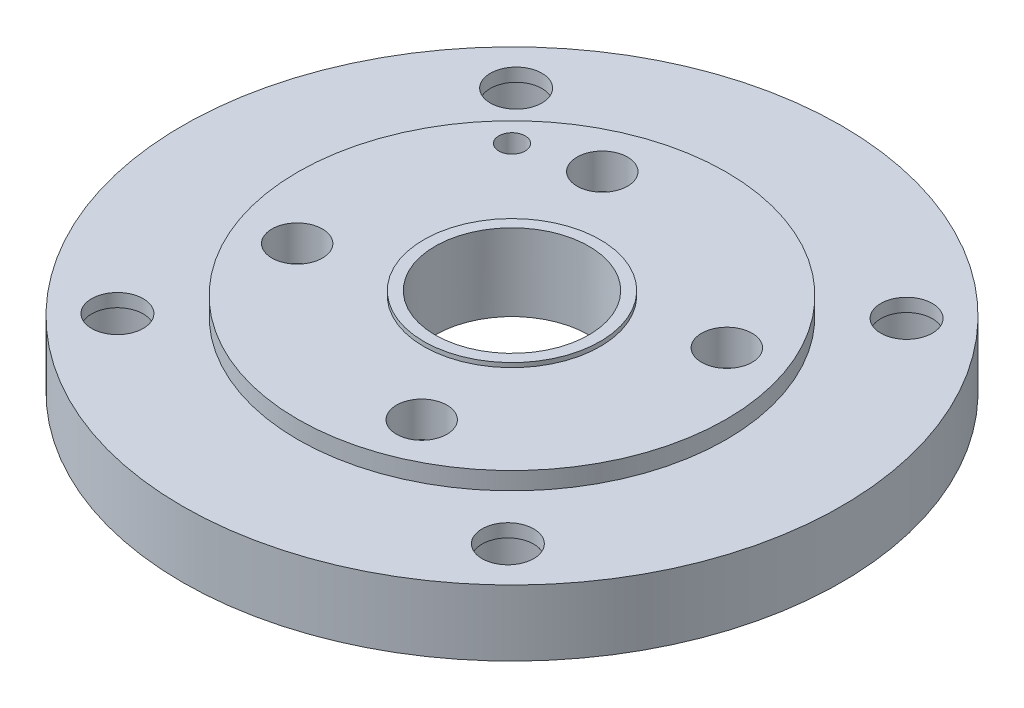
from build123d import *

# Parameters (mm, degrees)
IZIM1_R                     = 150
Y_KSEKLIK_EKSTR_ZYON1_DEPTH = 30
IZIM2_R                     = 97.5
Y_KSEKLIK_EKSTR_ZYON2_DEPTH = 8
IZIM3_R                     = 40.15
Y_KSEKLIK_EKSTR_ZYON3_DEPTH = 2
IZIM4_R                     = 35
KES_EKSTR_ZYON1_DEPTH       = 41
IZIM5_R                     = 43.5
KES_EKSTR_ZYON2_DEPTH       = 5
IZIM6_R                     = 11.5
IZIM6_R_2                   = 6
KES_EKSTR_ZYON4_DEPTH       = 16
IZIM7_R                     = 11.75
KES_EKSTR_ZYON5_DEPTH       = 31
IZIM8_R                     = 6
KES_EKSTR_ZYON6_DEPTH       = 23
IZIM9_R                     = 17.5
KES_EKSTR_ZYON7_DEPTH       = 24


with BuildPart() as part:
    # Çizim1 → Yükseklik-Ekstrüzyon1 (new body)
    with BuildSketch(Plane(origin=(0, 0, 0), x_dir=(1, 0, 0), z_dir=(0, 1, 0))):
        Circle(IZIM1_R)
    extrude(amount=Y_KSEKLIK_EKSTR_ZYON1_DEPTH)

    # Çizim2 → Yükseklik-Ekstrüzyon2 (add)
    with BuildSketch(Plane(origin=(0, 30, 0), x_dir=(1, 0, 0), z_dir=(0, 1, 0))):
        Circle(IZIM2_R)
    extrude(amount=Y_KSEKLIK_EKSTR_ZYON2_DEPTH)

    # Çizim3 → Yükseklik-Ekstrüzyon3 (add)
    with BuildSketch(Plane(origin=(0, 38, 0), x_dir=(1, 0, 0), z_dir=(0, 1, 0))):
        Circle(IZIM3_R)
    extrude(amount=Y_KSEKLIK_EKSTR_ZYON3_DEPTH)

    # Çizim4 → Kes-Ekstrüzyon1 (cut, through all)
    with BuildSketch(Plane(origin=(0, 40, 0), x_dir=(1, 0, 0), z_dir=(0, 1, 0))):
        Circle(IZIM4_R)
    extrude(amount=-KES_EKSTR_ZYON1_DEPTH, mode=Mode.SUBTRACT)

    # Çizim5 → Kes-Ekstrüzyon2 (cut)
    with BuildSketch(Plane.XZ):
        Circle(IZIM5_R)
    extrude(amount=-KES_EKSTR_ZYON2_DEPTH, mode=Mode.SUBTRACT)

    # Çizim6 → Kes-Ekstrüzyon4 (cut)
    with BuildSketch(Plane(origin=(0, 38, 0), x_dir=(1, 0, 0), z_dir=(0, 1, 0))):
        with Locations((-28.338059011, 69.440293861)):
            Circle(IZIM6_R)
        with Locations((69.440293861, 28.338059011)):
            Circle(IZIM6_R)
        with Locations((28.338059011, -69.440293861)):
            Circle(IZIM6_R)
        with Locations((-69.440293861, -28.338059011)):
            Circle(IZIM6_R)
        with Locations((-60, 60)):
            Circle(IZIM6_R_2)
    extrude(amount=-KES_EKSTR_ZYON4_DEPTH, mode=Mode.SUBTRACT)

    # Çizim7 → Kes-Ekstrüzyon5 (cut, through all)
    with BuildSketch(Plane(origin=(0, 30, 0), x_dir=(1, 0, 0), z_dir=(0, 1, 0))):
        with Locations((-88.857244245, 90.738030313)):
            Circle(IZIM7_R)
        with Locations((90.738030313, 88.857244245)):
            Circle(IZIM7_R)
        with Locations((88.857244245, -90.738030313)):
            Circle(IZIM7_R)
        with Locations((-90.738030313, -88.857244245)):
            Circle(IZIM7_R)
    extrude(amount=-KES_EKSTR_ZYON5_DEPTH, mode=Mode.SUBTRACT)

    # Çizim8 → Kes-Ekstrüzyon6 (cut, through all)
    with BuildSketch(Plane(origin=(0, 22, 0), x_dir=(1, 0, 0), z_dir=(0, 1, 0))):
        with Locations((-60, 60)):
            Circle(IZIM8_R)
    extrude(amount=-KES_EKSTR_ZYON6_DEPTH, mode=Mode.SUBTRACT)

    # Çizim9 → Kes-Ekstrüzyon7 (cut)
    with BuildSketch(Plane.XZ):
        with Locations((-90.738030313, 88.857244245)):
            Circle(IZIM9_R)
        with Locations((88.857244245, 90.738030313)):
            Circle(IZIM9_R)
        with Locations((90.738030313, -88.857244245)):
            Circle(IZIM9_R)
        with Locations((-88.857244245, -90.738030313)):
            Circle(IZIM9_R)
    extrude(amount=-KES_EKSTR_ZYON7_DEPTH, mode=Mode.SUBTRACT)


solid = part.part
